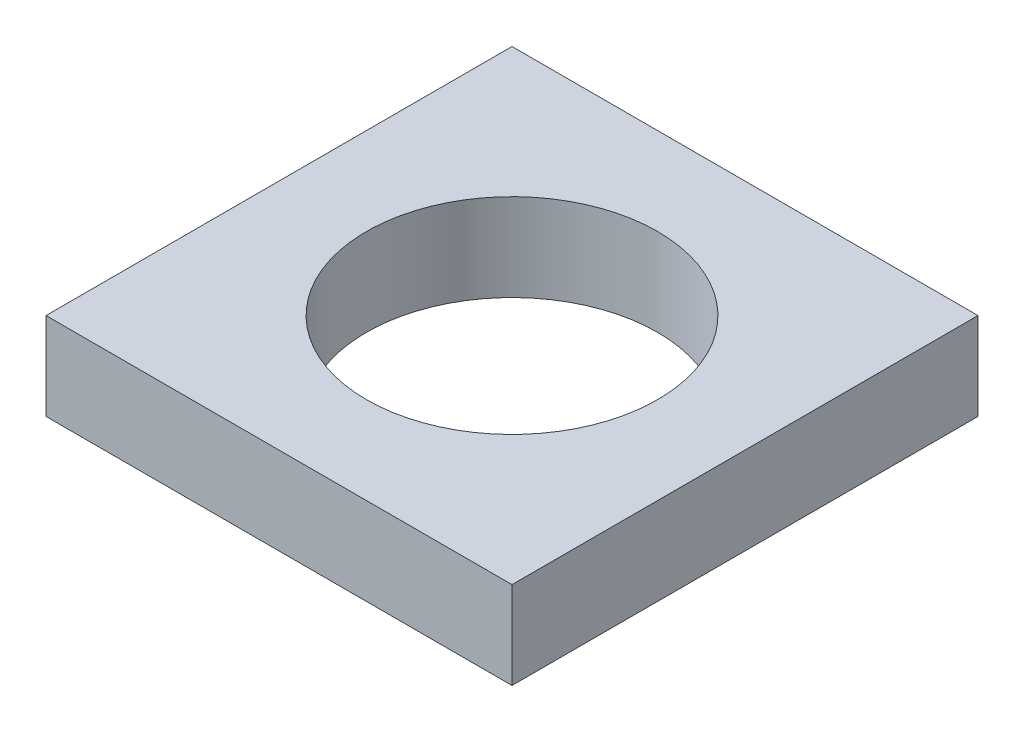
from build123d import *

# Parameters (mm, degrees)
SKETCH2_R                = 42.4942
SKETCH2_R_2              = 40.005
BOSS_EXTRUDE1_DEPTH      = 9.525
SKETCH2_4_R              = 40.005
SKETCH2_4_R_2            = 37.9984
BOSS_EXTRUDE2_DEPTH      = 2.54
BOSS_EXTRUDE3_START      = -7.62
SKETCH2_5_R              = 40.5003
SKETCH2_5_R_2            = 37.9984
BOSS_EXTRUDE3_DEPTH      = 7.62
BOSS_EXTRUDE4_DEPTH      = 10.16
BOSS_EXTRUDE4_DEPTH_BACK = 8.89
SKETCH3_W                = 101.6
SKETCH3_H                = 101.6
SKETCH3_R                = 31.75


with BuildPart() as part:
    # Sketch2 → Boss-Extrude1 (new body)
    with BuildSketch(Plane(origin=(0, 0, 0), x_dir=(1, 0, 0), z_dir=(0, 1, 0))):
        Circle(SKETCH2_R)
        Circle(SKETCH2_R_2, mode=Mode.SUBTRACT)
    extrude(amount=BOSS_EXTRUDE1_DEPTH)

    # Sketch2_4 → Boss-Extrude2 (add)
    with BuildSketch(Plane(origin=(0, 0, 0), x_dir=(1, 0, 0), z_dir=(0, 1, 0))):
        Circle(SKETCH2_4_R)
        Circle(SKETCH2_4_R_2, mode=Mode.SUBTRACT)
    extrude(amount=BOSS_EXTRUDE2_DEPTH)

    # Sketch2_5 → Boss-Extrude3 (add)
    with BuildSketch(Plane(origin=(0, 0, 0), x_dir=(1, 0, 0), z_dir=(0, 1, 0)).offset(BOSS_EXTRUDE3_START)):
        Circle(SKETCH2_5_R)
        Circle(SKETCH2_5_R_2, mode=Mode.SUBTRACT)
    extrude(amount=BOSS_EXTRUDE3_DEPTH)


with BuildPart() as body_2:
    # Sketch3 → Boss-Extrude4 (new, two sides: drawn at the far end of the back side and taken through both)
    with BuildSketch(Plane(origin=(0, 0, 0), x_dir=(1, 0, 0), z_dir=(0, 1, 0)).offset(-BOSS_EXTRUDE4_DEPTH_BACK)):
        Rectangle(SKETCH3_W, SKETCH3_H)
        Circle(SKETCH3_R, mode=Mode.SUBTRACT)
    extrude(amount=BOSS_EXTRUDE4_DEPTH + BOSS_EXTRUDE4_DEPTH_BACK)


solid = Compound([part.part, body_2.part])
